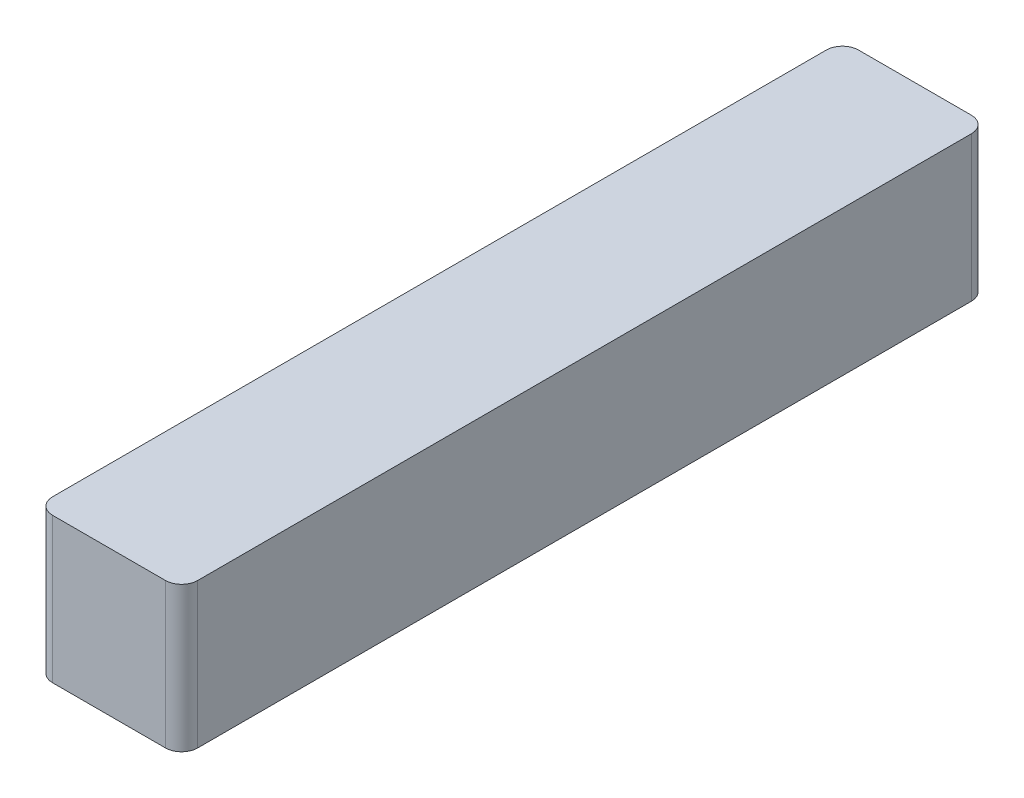
from build123d import *

# Parameters (mm, degrees)
SKETCH1_W           = 2.286
SKETCH1_H           = 2.286
BOSS_EXTRUDE1_DEPTH = 12.7
FILLET1_R           = 0.254


with BuildPart() as part:
    # Sketch1 → Boss-Extrude1 (new body)
    with BuildSketch(Plane.XY):
        Rectangle(SKETCH1_W, SKETCH1_H)
    extrude(amount=BOSS_EXTRUDE1_DEPTH)

    # Fillet1
    fillet1_edges = [part.edges().sort_by_distance(p)[0] for p in [
        (-1.143, 0, 12.7),
        (1.143, 0, 12.7),
        (-1.143, 0, 0),
        (1.143, 0, 0),
    ]]
    fillet(fillet1_edges, radius=FILLET1_R)


solid = part.part
